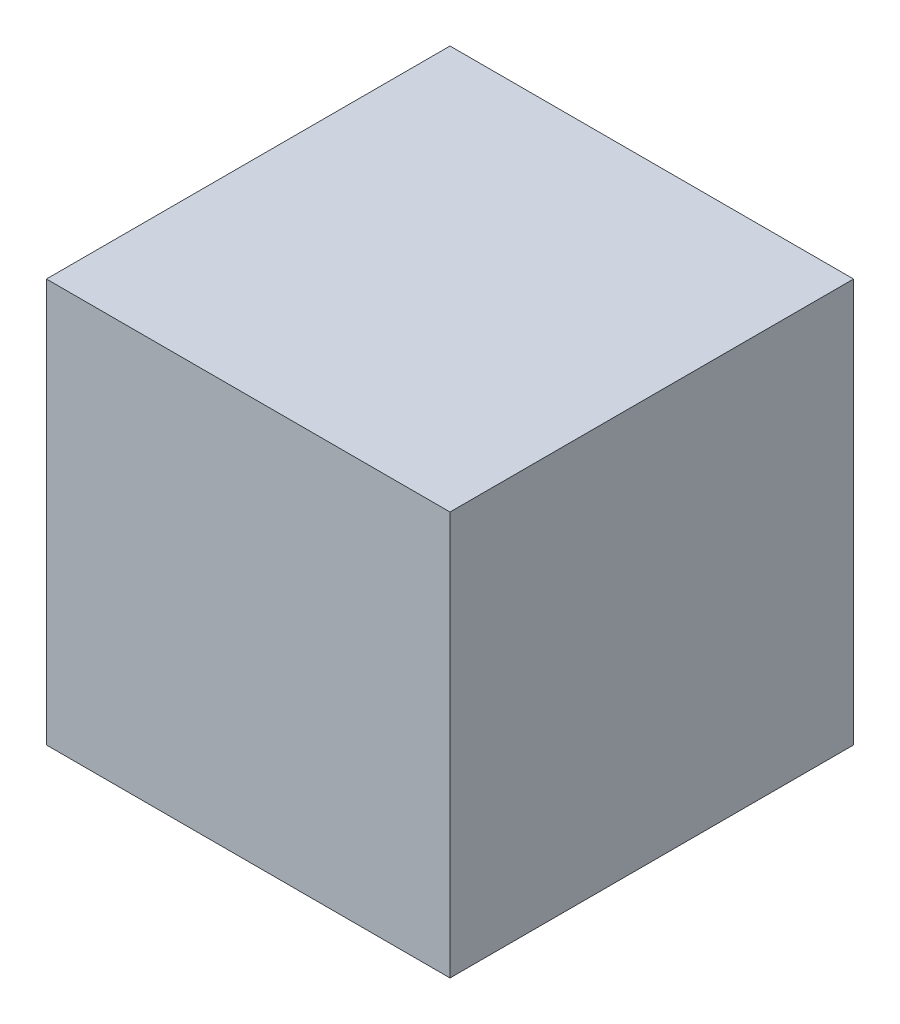
from build123d import *

# Parameters (mm, degrees)
SKETCH1_W      = 228.6
SKETCH1_H      = 228.6
EXTRUDE1_DEPTH = 228.6


with BuildPart() as part:
    # Sketch1 → Extrude1 (new body)
    with BuildSketch(Plane(origin=(0, 0, 0), x_dir=(1, 0, 0), z_dir=(0, 1, 0))):
        with Locations((114.3, 114.3)):
            Rectangle(SKETCH1_W, SKETCH1_H)
    extrude(amount=EXTRUDE1_DEPTH)


solid = part.part
